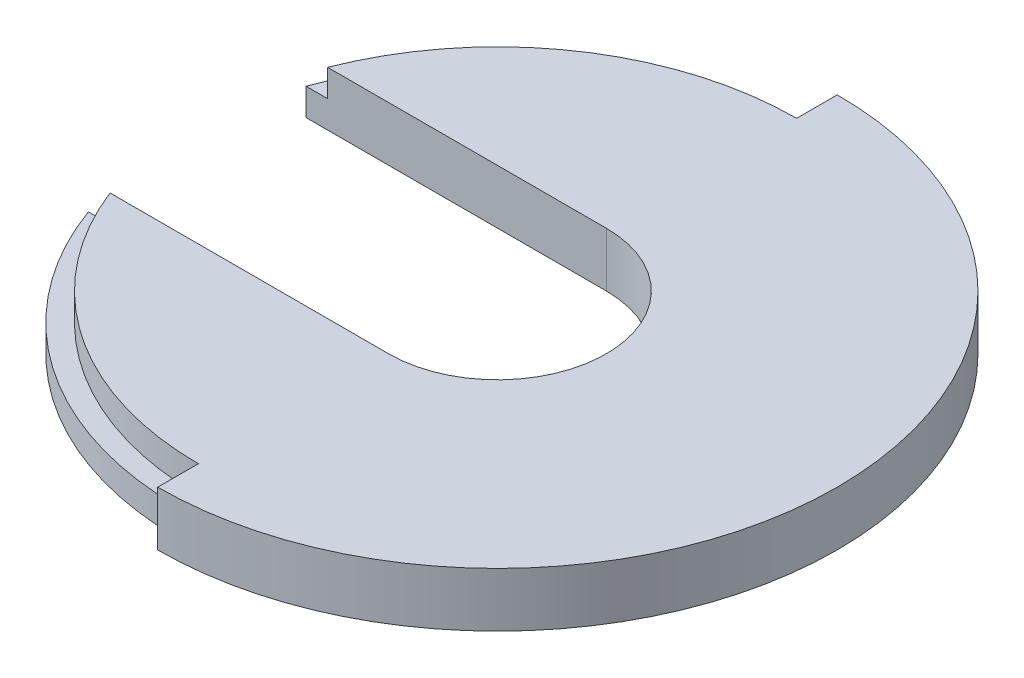
from build123d import *

# Parameters (mm, degrees)
BOSS_EXTRUDE1_DEPTH = 2
BOSS_EXTRUDE2_START = 1
SKETCH1_5_R         = 11.75
BOSS_EXTRUDE2_DEPTH = 1
CUT_EXTRUDE4_DEPTH  = 11
BOSS_EXTRUDE3_DEPTH = 1
BOSS_EXTRUDE4_DEPTH = 1
CUT_EXTRUDE5_START  = 2
CUT_EXTRUDE5_DEPTH  = 1
BOSS_EXTRUDE5_DEPTH = 2


with BuildPart() as part:
    # Sketch1 → Boss-Extrude1 (new body)
    with BuildSketch(Plane(origin=(0, 0, 0), x_dir=(1, 0, 0), z_dir=(0, 1, 0))):
        with BuildLine():
            Line((0, 12.5), (0, 11.75))
            ThreePointArc((0, 11.75), (8.308504679, 8.308504679), (11.75, 0))
            ThreePointArc((11.75, 0), (8.308504679, -8.308504679), (0, -11.75))
            Line((0, -11.75), (0, -12.5))
            ThreePointArc((0, -12.5), (8.838834765, -8.838834765), (12.5, 0))
            ThreePointArc((12.5, 0), (8.838834765, 8.838834765), (0, 12.5))
        make_face()
        with BuildLine():
            Line((0, 11.75), (0, 11.0045))
            ThreePointArc((0, 11.0045), (7.781356574, 7.781356574), (11.0045, 0))
            ThreePointArc((11.0045, 0), (7.781356574, -7.781356574), (0, -11.0045))
            Line((0, -11.0045), (0, -11.75))
            ThreePointArc((0, -11.75), (8.308504679, -8.308504679), (11.75, 0))
            ThreePointArc((11.75, 0), (8.308504679, 8.308504679), (0, 11.75))
        make_face()
    extrude(amount=BOSS_EXTRUDE1_DEPTH)

    # Sketch1_5 → Boss-Extrude2 (add)
    with BuildSketch(Plane(origin=(0, 0, 0), x_dir=(1, 0, 0), z_dir=(0, 1, 0)).offset(BOSS_EXTRUDE2_START)):
        Circle(SKETCH1_5_R)
    extrude(amount=BOSS_EXTRUDE2_DEPTH)

    # Sketch1_8 → Cut-Extrude4 (cut)
    with BuildSketch(Plane(origin=(0, 0, 0), x_dir=(1, 0, 0), z_dir=(0, 1, 0))):
        with BuildLine():
            ThreePointArc((4.0025, 0), (2.830194892, 2.830194892), (0, 4.0025))
            Line((0, 4.0025), (0, -4.0025))
            ThreePointArc((0, -4.0025), (2.830194892, -2.830194892), (4.0025, 0))
        make_face()
        with BuildLine():
            Line((0, -4.0025), (0, 4.0025))
            ThreePointArc((0, 4.0025), (-4.0025, 0), (0, -4.0025))
        make_face()
        with BuildLine():
            ThreePointArc((0, -4.0025), (-4.0025, 0), (0, 4.0025))
            Line((0, 4.0025), (-10.250805529, 4.0025))
            ThreePointArc((-10.250805529, 4.0025), (-11.0045, 0), (-10.250805529, -4.0025))
            Line((-10.250805529, -4.0025), (0, -4.0025))
        make_face()
        with BuildLine():
            ThreePointArc((-10.250805529, -4.0025), (-11.0045, 0), (-10.250805529, 4.0025))
            Line((-10.250805529, 4.0025), (-11.047284451, 4.0025))
            ThreePointArc((-11.047284451, 4.0025), (-11.75, 0), (-11.047284451, -4.0025))
            Line((-11.047284451, -4.0025), (-10.250805529, -4.0025))
        make_face()
    extrude(amount=CUT_EXTRUDE4_DEPTH, mode=Mode.SUBTRACT)

    # Sketch1_9 → Boss-Extrude3 (add)
    with BuildSketch(Plane(origin=(0, 0, 0), x_dir=(1, 0, 0), z_dir=(0, 1, 0))):
        with BuildLine():
            Line((0, 11.0045), (0, 4.0025))
            ThreePointArc((0, 4.0025), (2.830194892, 2.830194892), (4.0025, 0))
            ThreePointArc((4.0025, 0), (2.830194892, -2.830194892), (0, -4.0025))
            Line((0, -4.0025), (0, -11.0045))
            ThreePointArc((0, -11.0045), (7.781356574, -7.781356574), (11.0045, 0))
            ThreePointArc((11.0045, 0), (7.781356574, 7.781356574), (0, 11.0045))
        make_face()
    extrude(amount=BOSS_EXTRUDE3_DEPTH)

    # Sketch1_10 → Boss-Extrude4 (add)
    with BuildSketch(Plane(origin=(0, 0, 0), x_dir=(1, 0, 0), z_dir=(0, 1, 0))):
        with BuildLine():
            Line((-10.250805529, 4.0025), (0, 4.0025))
            Line((0, 4.0025), (0, 11.0045))
            ThreePointArc((0, 11.0045), (-6.206992388, 9.08692829), (-10.250805529, 4.0025))
        make_face()
        with BuildLine():
            Line((0, -11.0045), (0, -4.0025))
            Line((0, -4.0025), (-10.250805529, -4.0025))
            ThreePointArc((-10.250805529, -4.0025), (-6.206992388, -9.08692829), (0, -11.0045))
        make_face()
        with BuildLine():
            Line((0, -11.75), (0, -11.0045))
            ThreePointArc((0, -11.0045), (-6.206992388, -9.08692829), (-10.250805529, -4.0025))
            Line((-10.250805529, -4.0025), (-11.047284451, -4.0025))
            ThreePointArc((-11.047284451, -4.0025), (-6.746596364, -9.620079911), (0, -11.75))
        make_face()
        with BuildLine():
            ThreePointArc((-10.250805529, 4.0025), (-6.206992388, 9.08692829), (0, 11.0045))
            Line((0, 11.0045), (0, 11.75))
            ThreePointArc((0, 11.75), (-6.746596364, 9.620079911), (-11.047284451, 4.0025))
            Line((-11.047284451, 4.0025), (-10.250805529, 4.0025))
        make_face()
    extrude(amount=BOSS_EXTRUDE4_DEPTH)

    # Sketch1_11 → Cut-Extrude5 (cut)
    with BuildSketch(Plane(origin=(0, 0, 0), x_dir=(1, 0, 0), z_dir=(0, 1, 0)).offset(CUT_EXTRUDE5_START)):
        with BuildLine():
            Line((-10.250805529, 4.0025), (0, 4.0025))
            Line((0, 4.0025), (0, 11.0045))
            ThreePointArc((0, 11.0045), (-6.206992388, 9.08692829), (-10.250805529, 4.0025))
        make_face()
        with BuildLine():
            ThreePointArc((-10.250805529, 4.0025), (-6.206992388, 9.08692829), (0, 11.0045))
            Line((0, 11.0045), (0, 11.75))
            ThreePointArc((0, 11.75), (-6.746596364, 9.620079911), (-11.047284451, 4.0025))
            Line((-11.047284451, 4.0025), (-10.250805529, 4.0025))
        make_face()
        with BuildLine():
            Line((0, -11.0045), (0, -4.0025))
            Line((0, -4.0025), (-10.250805529, -4.0025))
            ThreePointArc((-10.250805529, -4.0025), (-6.206992388, -9.08692829), (0, -11.0045))
        make_face()
        with BuildLine():
            Line((0, -11.75), (0, -11.0045))
            ThreePointArc((0, -11.0045), (-6.206992388, -9.08692829), (-10.250805529, -4.0025))
            Line((-10.250805529, -4.0025), (-11.047284451, -4.0025))
            ThreePointArc((-11.047284451, -4.0025), (-6.746596364, -9.620079911), (0, -11.75))
        make_face()
    extrude(amount=-CUT_EXTRUDE5_DEPTH, mode=Mode.SUBTRACT)

    # Sketch1_12 → Boss-Extrude5 (add)
    with BuildSketch(Plane(origin=(0, 0, 0), x_dir=(1, 0, 0), z_dir=(0, 1, 0))):
        with BuildLine():
            Line((0, -11.0045), (0, -4.0025))
            Line((0, -4.0025), (-10.250805529, -4.0025))
            ThreePointArc((-10.250805529, -4.0025), (-6.206992388, -9.08692829), (0, -11.0045))
        make_face()
        with BuildLine():
            Line((-10.250805529, 4.0025), (0, 4.0025))
            Line((0, 4.0025), (0, 11.0045))
            ThreePointArc((0, 11.0045), (-6.206992388, 9.08692829), (-10.250805529, 4.0025))
        make_face()
    extrude(amount=BOSS_EXTRUDE5_DEPTH)


solid = part.part
